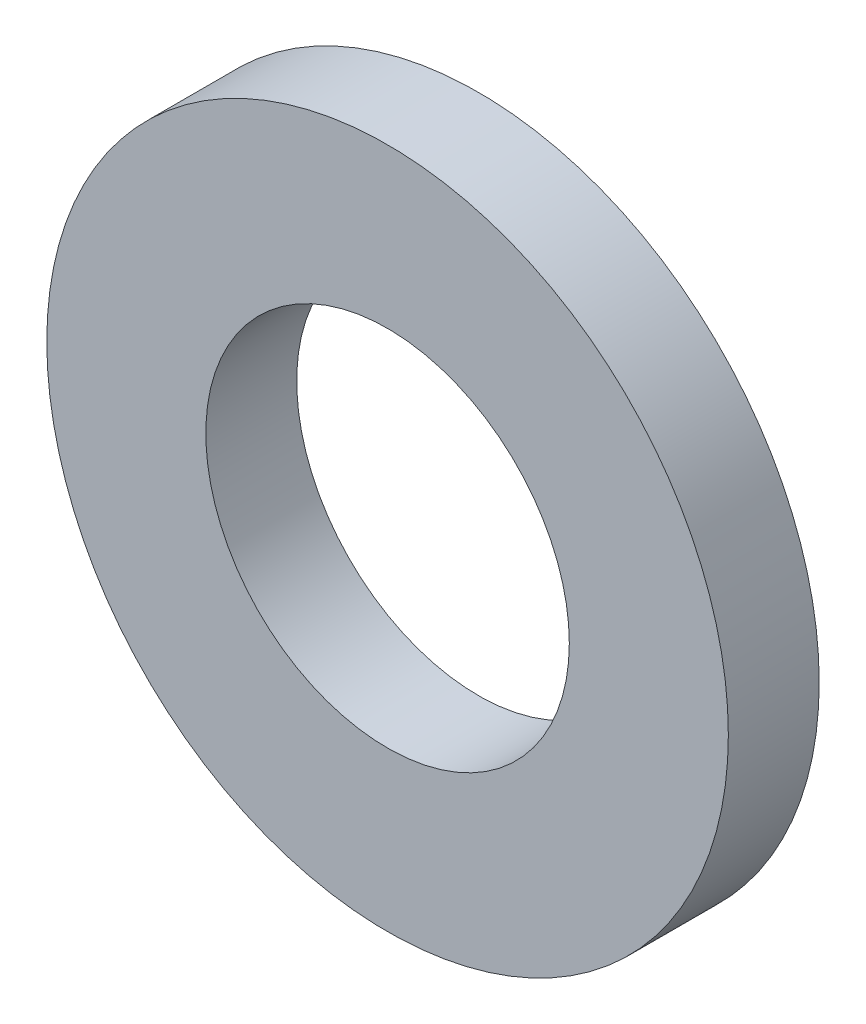
from build123d import *

# Parameters (mm, degrees)
SKETCH3_R                = 6
SKETCH3_R_2              = 3.2
BOSS_EXTRUDE1_DEPTH      = 0.8
BOSS_EXTRUDE1_DEPTH_BACK = 0.8


with BuildPart() as part:
    # Sketch3 → Boss-Extrude1 (new body, two sides)
    with BuildSketch(Plane.XY) as boss_extrude1_sk:
        Circle(SKETCH3_R)
        Circle(SKETCH3_R_2, mode=Mode.SUBTRACT)
    extrude(amount=BOSS_EXTRUDE1_DEPTH)
    extrude(boss_extrude1_sk.sketch, amount=-BOSS_EXTRUDE1_DEPTH_BACK)


solid = part.part
